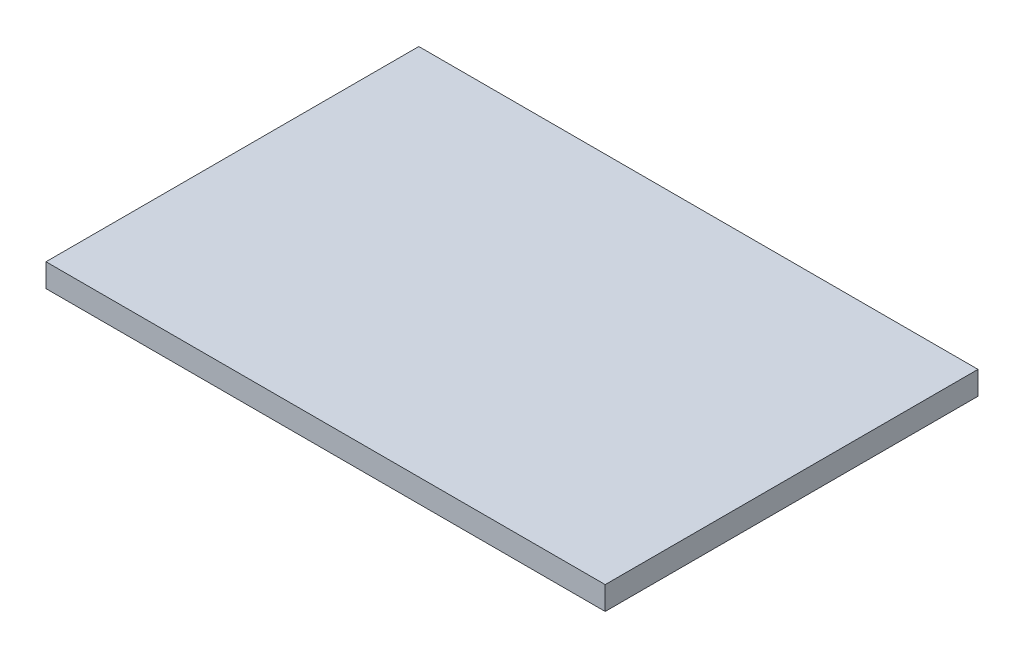
from build123d import *

# Parameters (mm, degrees)
SKETCH1_W           = 152.4
SKETCH1_H           = 101.6
BOSS_EXTRUDE1_DEPTH = 6.35


with BuildPart() as part:
    # Sketch1 → Boss-Extrude1 (new body)
    with BuildSketch(Plane(origin=(0, 0, 0), x_dir=(1, 0, 0), z_dir=(0, 1, 0))):
        with Locations((76.2, 50.8)):
            Rectangle(SKETCH1_W, SKETCH1_H)
    extrude(amount=BOSS_EXTRUDE1_DEPTH)


solid = part.part
